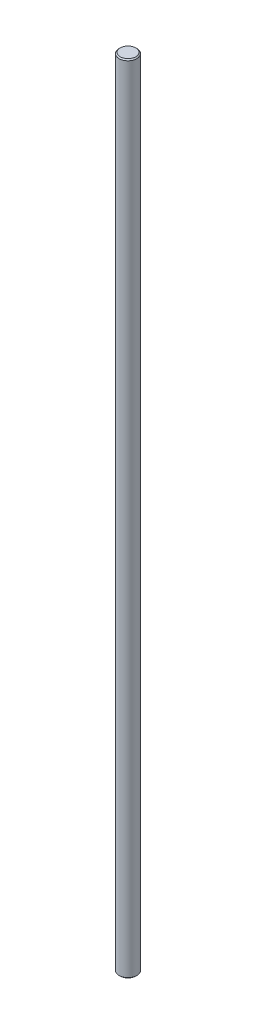
from build123d import *

# Parameters (mm, degrees)
BOSS_EXTRUDE1_DEPTH      = 180
BOSS_EXTRUDE1_DEPTH_BACK = 180
SKETCH1_R                = 4
CHAMFER1_SIZE            = 0.5


with BuildPart() as part:
    # Sketch1 → Boss-Extrude1 (new, two sides: drawn at the far end of the back side and taken through both)
    with BuildSketch(Plane(origin=(0, 0, 0), x_dir=(1, 0, 0), z_dir=(0, 1, 0)).offset(-BOSS_EXTRUDE1_DEPTH_BACK)):
        Circle(SKETCH1_R)
    extrude(amount=BOSS_EXTRUDE1_DEPTH + BOSS_EXTRUDE1_DEPTH_BACK)

    # Chamfer1
    chamfer1_edges = [part.edges().sort_by_distance(p)[0] for p in [
        (-4, -180, 0),
        (-4, 180, 0),
    ]]
    chamfer(chamfer1_edges, length=CHAMFER1_SIZE)


solid = part.part
